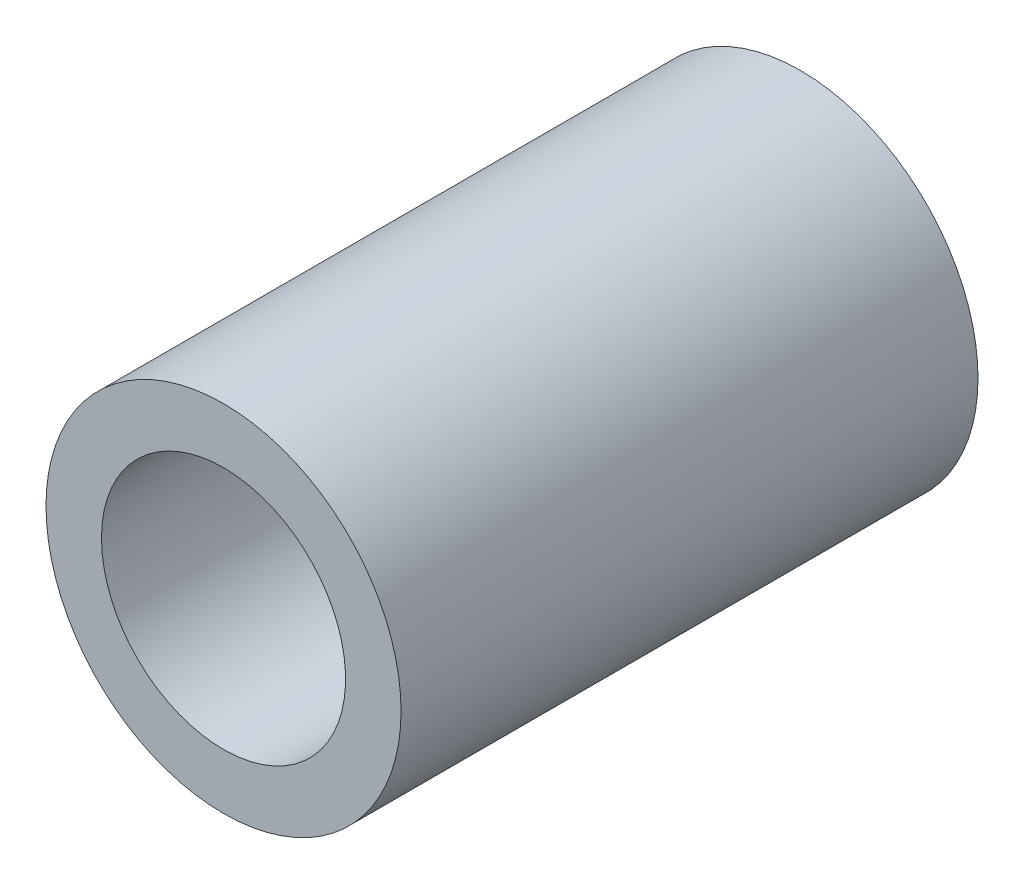
from build123d import *

# Parameters (mm, degrees)
SKETCH1_R           = 16
BOSS_EXTRUDE1_DEPTH = 52
SKETCH2_R           = 11
CUT_EXTRUDE1_DEPTH  = 52


with BuildPart() as part:
    # Sketch1 → Boss-Extrude1 (new body)
    with BuildSketch(Plane.XY):
        Circle(SKETCH1_R)
    extrude(amount=BOSS_EXTRUDE1_DEPTH)

    # Sketch2 → Cut-Extrude1 (cut)
    with BuildSketch(Plane(origin=(0, 0, 0), x_dir=(-1, 0, 0), z_dir=(0, 0, -1))):
        Circle(SKETCH2_R)
    extrude(amount=-CUT_EXTRUDE1_DEPTH, mode=Mode.SUBTRACT)


solid = part.part
